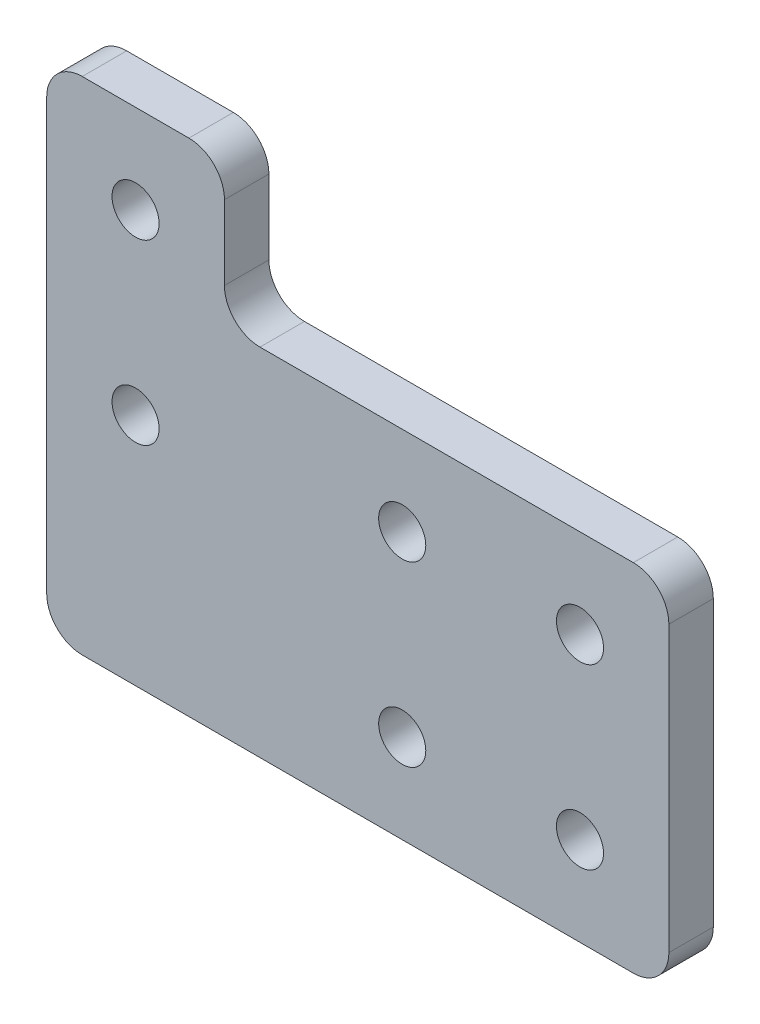
from build123d import *

# Parameters (mm, degrees)
END_CAP_SKETCH_R        = 2.65
EXTRUDE_THICKNESS_DEPTH = 5


with BuildPart() as part:
    # End Cap Sketch → Extrude Thickness (new body)
    with BuildSketch(Plane.XY):
        with BuildLine():
            Line((-46, -20), (16, -20))
            ThreePointArc((16, -20), (18.828427125, -18.828427125), (20, -16))
            Line((20, -16), (20, 16))
            ThreePointArc((20, 16), (18.828427125, 18.828427125), (16, 20))
            Line((16, 20), (-26, 20))
            ThreePointArc((-26, 20), (-28.828427125, 21.171572875), (-30, 24))
            Line((-30, 24), (-30, 32.365))
            ThreePointArc((-30, 32.365), (-31.171572875, 35.193427125), (-34, 36.365))
            Line((-34, 36.365), (-46, 36.365))
            ThreePointArc((-46, 36.365), (-48.828427125, 35.193427125), (-50, 32.365))
            Line((-50, 32.365), (-50, -16))
            ThreePointArc((-50, -16), (-48.828427125, -18.828427125), (-46, -20))
        make_face()
        with Locations((-10, 10)):
            Circle(END_CAP_SKETCH_R, mode=Mode.SUBTRACT)
        with Locations((-10, -10)):
            Circle(END_CAP_SKETCH_R, mode=Mode.SUBTRACT)
        with Locations((10, 10)):
            Circle(END_CAP_SKETCH_R, mode=Mode.SUBTRACT)
        with Locations((10, -10)):
            Circle(END_CAP_SKETCH_R, mode=Mode.SUBTRACT)
        with Locations((-40, 26.365)):
            Circle(END_CAP_SKETCH_R, mode=Mode.SUBTRACT)
        with Locations((-40, 6.365)):
            Circle(END_CAP_SKETCH_R, mode=Mode.SUBTRACT)
    extrude(amount=EXTRUDE_THICKNESS_DEPTH)


solid = part.part
